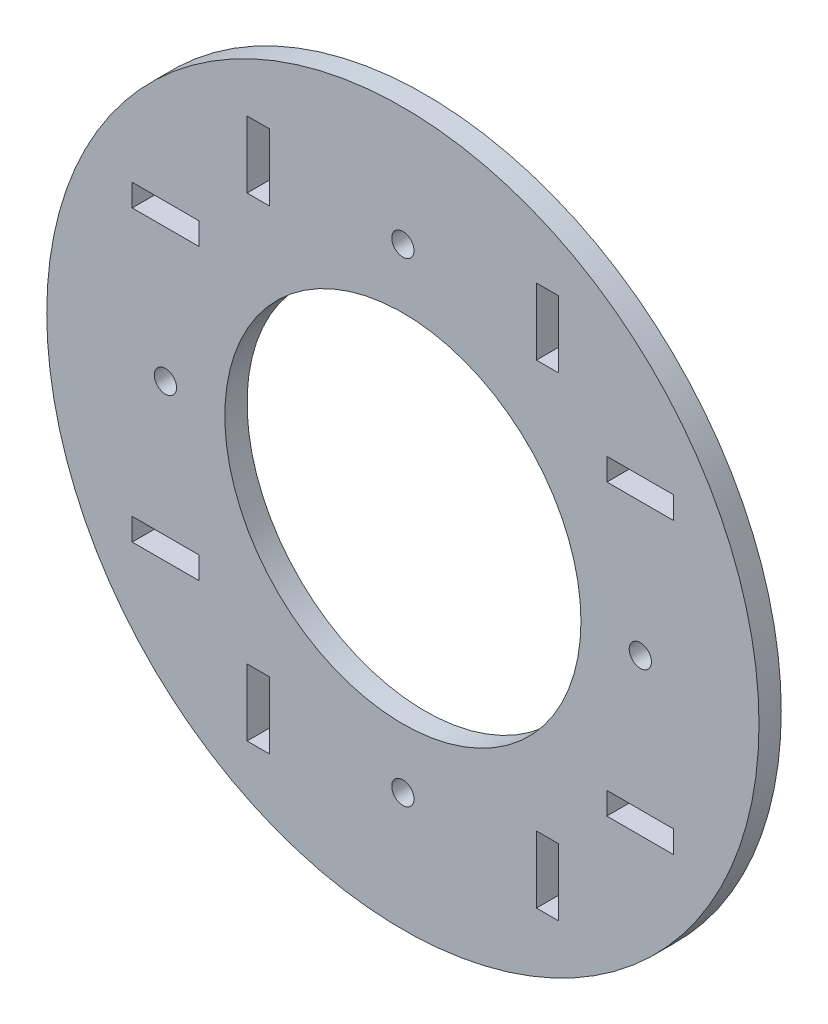
from build123d import *

# Parameters (mm, degrees)
SKETCH1_R           = 50.8
SKETCH1_R_2         = 25.4
SKETCH1_R_3         = 1.5875
SKETCH1_W           = 9.525
SKETCH1_H           = 3.175
SKETCH1_W_2         = 3.175
SKETCH1_H_2         = 9.525
BOSS_EXTRUDE1_DEPTH = 3.175


with BuildPart() as part:
    # Sketch1 → Boss-Extrude1 (new body)
    with BuildSketch(Plane.XY):
        with Locations((-3.17373, 0)):
            Circle(SKETCH1_R)
        with Locations((-3.17373, 0)):
            Circle(SKETCH1_R_2, mode=Mode.SUBTRACT)
        with Locations((-3.17373, -33.8709)):
            Circle(SKETCH1_R_3, mode=Mode.SUBTRACT)
        with Locations((30.69717, 0)):
            Circle(SKETCH1_R_3, mode=Mode.SUBTRACT)
        with Locations((-37.04463, 0)):
            Circle(SKETCH1_R_3, mode=Mode.SUBTRACT)
        with Locations((-3.17373, 33.8709)):
            Circle(SKETCH1_R_3, mode=Mode.SUBTRACT)
        with Locations((-37.01923, -20.6375)):
            Rectangle(SKETCH1_W, SKETCH1_H, mode=Mode.SUBTRACT)
        with Locations((-37.01923, 20.6375)):
            Rectangle(SKETCH1_W, SKETCH1_H, mode=Mode.SUBTRACT)
        with Locations((-23.81123, 33.8455)):
            Rectangle(SKETCH1_W_2, SKETCH1_H_2, mode=Mode.SUBTRACT)
        with Locations((17.46377, 33.8455)):
            Rectangle(SKETCH1_W_2, SKETCH1_H_2, mode=Mode.SUBTRACT)
        with Locations((17.46377, -33.8455)):
            Rectangle(SKETCH1_W_2, SKETCH1_H_2, mode=Mode.SUBTRACT)
        with Locations((-23.81123, -33.8455)):
            Rectangle(SKETCH1_W_2, SKETCH1_H_2, mode=Mode.SUBTRACT)
        with Locations((30.67177, -20.6375)):
            Rectangle(SKETCH1_W, SKETCH1_H, mode=Mode.SUBTRACT)
        with Locations((30.69717, 20.6375)):
            Rectangle(SKETCH1_W, SKETCH1_H, mode=Mode.SUBTRACT)
    extrude(amount=BOSS_EXTRUDE1_DEPTH)


solid = part.part
